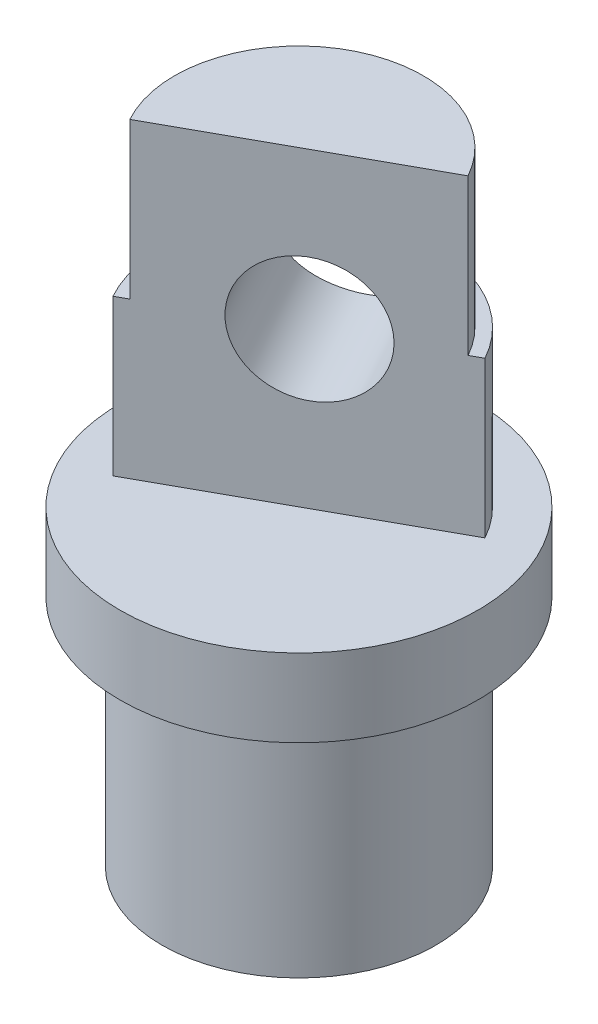
from build123d import *

# Parameters (mm, degrees)
BOSS_EXTRUDE1_DEPTH = 10
SKETCH1_4_R         = 11.5
BOSS_EXTRUDE3_DEPTH = 5
BOSS_EXTRUDE4_DEPTH = 5
BOSS_EXTRUDE5_DEPTH = 20
SKETCH1_8_R         = 11.5
SKETCH1_8_R_2       = 8.8
SKETCH1_8_R_3       = 8
BOSS_EXTRUDE6_DEPTH = 5
SKETCH1_10_R        = 8.8
SKETCH1_10_R_2      = 8
BOSS_EXTRUDE8_DEPTH = 20
SKETCH8_R           = 4
CUT_EXTRUDE2_DEPTH  = 20


with BuildPart() as part:
    # Sketch1 → Boss-Extrude1 (new body)
    with BuildSketch(Plane(origin=(0, 0, 0), x_dir=(1, 0, 0), z_dir=(0, 1, 0))):
        with BuildLine():
            Line((-7.705545208, -4.250243881), (-7.005041098, -3.863858073))
            ThreePointArc((-7.005041098, -3.863858073), (-3.863858073, 7.005041098), (7.005041098, 3.863858073))
            Line((7.005041098, 3.863858073), (7.705545208, 4.250243881))
            ThreePointArc((7.705545208, 4.250243881), (-4.250243881, 7.705545208), (-7.705545208, -4.250243881))
        make_face()
    extrude(amount=BOSS_EXTRUDE1_DEPTH)

    # Sketch1_4 → Boss-Extrude3 (add)
    with BuildSketch(Plane(origin=(0, 0, 0), x_dir=(1, 0, 0), z_dir=(0, 1, 0))):
        Circle(SKETCH1_4_R)
        with BuildLine():
            Line((-7.705545208, -4.250243881), (-7.005041098, -3.863858073))
            ThreePointArc((-7.005041098, -3.863858073), (3.863858073, -7.005041098), (7.005041098, 3.863858073))
            Line((7.005041098, 3.863858073), (7.705545208, 4.250243881))
            ThreePointArc((7.705545208, 4.250243881), (4.250243881, -7.705545208), (-7.705545208, -4.250243881))
        make_face(mode=Mode.SUBTRACT)
    extrude(amount=-BOSS_EXTRUDE3_DEPTH)

    # Sketch1_6 → Boss-Extrude4 (add)
    with BuildSketch(Plane(origin=(0, 0, 0), x_dir=(1, 0, 0), z_dir=(0, 1, 0))):
        with BuildLine():
            ThreePointArc((8, 0), (1.994952532, -7.747268189), (-7.005041098, -3.863858073))
            Line((-7.005041098, -3.863858073), (-7.705545208, -4.250243881))
            ThreePointArc((-7.705545208, -4.250243881), (2.194447786, -8.521995008), (8.8, 0))
            ThreePointArc((8.8, 0), (8.521995008, 2.194447786), (7.705545208, 4.250243881))
            Line((7.705545208, 4.250243881), (7.005041098, 3.863858073))
            ThreePointArc((7.005041098, 3.863858073), (7.747268189, 1.994952532), (8, 0))
        make_face()
    extrude(amount=-BOSS_EXTRUDE4_DEPTH)

    # Sketch1_7 → Boss-Extrude5 (add)
    with BuildSketch(Plane(origin=(0, 0, 0), x_dir=(1, 0, 0), z_dir=(0, 1, 0))):
        with BuildLine():
            ThreePointArc((7.005041098, 3.863858073), (-3.863858073, 7.005041098), (-7.005041098, -3.863858073))
            Line((-7.005041098, -3.863858073), (7.005041098, 3.863858073))
        make_face()
    extrude(amount=BOSS_EXTRUDE5_DEPTH)

    # Sketch1_8 → Boss-Extrude6 (add)
    with BuildSketch(Plane(origin=(0, 0, 0), x_dir=(1, 0, 0), z_dir=(0, 1, 0))):
        Circle(SKETCH1_8_R)
        Circle(SKETCH1_8_R_2, mode=Mode.SUBTRACT)
        Circle(SKETCH1_8_R_3)
    extrude(amount=-BOSS_EXTRUDE6_DEPTH)

    # Sketch1_10 → Boss-Extrude8 (add)
    with BuildSketch(Plane(origin=(0, 0, 0), x_dir=(1, 0, 0), z_dir=(0, 1, 0))):
        Circle(SKETCH1_10_R)
        Circle(SKETCH1_10_R_2, mode=Mode.SUBTRACT)
    extrude(amount=-BOSS_EXTRUDE8_DEPTH)

    # Sketch8 → Cut-Extrude2 (cut)
    with BuildSketch(Plane(origin=(0, 0, 0), x_dir=(0.875630137, 0, -0.482982259), z_dir=(0.482982259, 0, 0.875630137))):
        with Locations((0.5, 10)):
            Circle(SKETCH8_R)
    extrude(amount=-CUT_EXTRUDE2_DEPTH, mode=Mode.SUBTRACT)


solid = part.part
